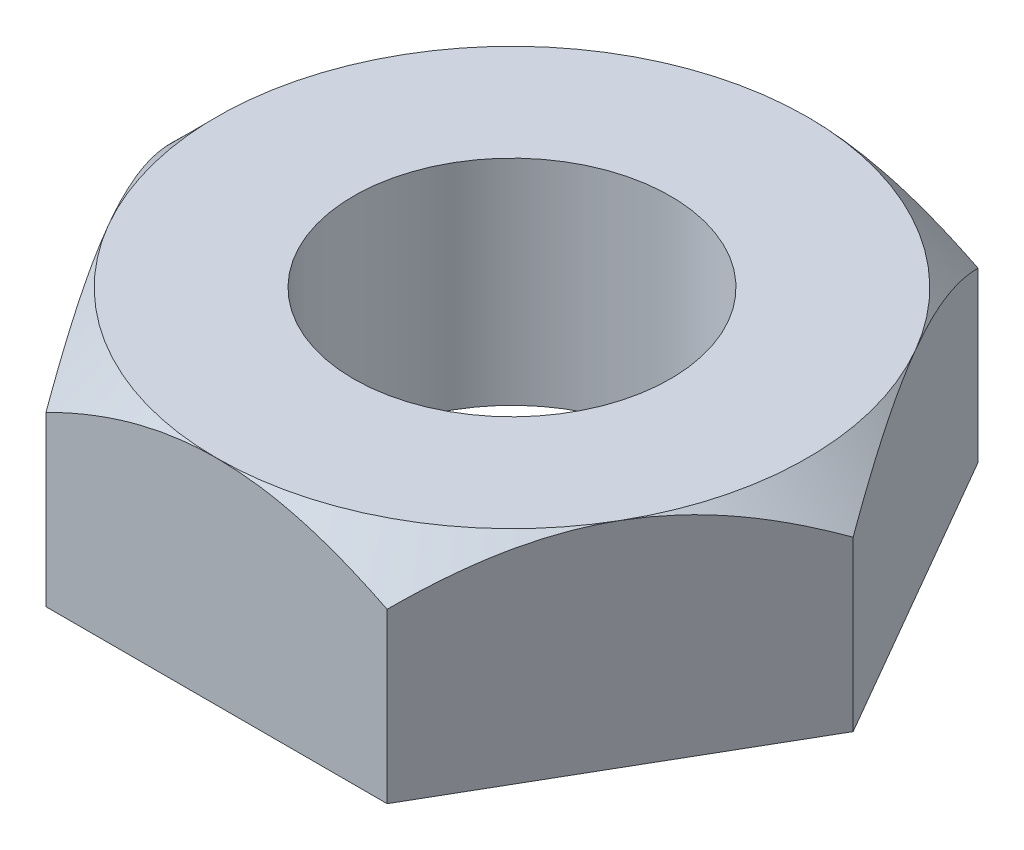
from build123d import *

# Parameters (mm, degrees)
SKETCH1_R                    = 18.5
BOSS_EXTRUDE1_DEPTH          = 25
SKETCH2_OUTSIDE_W            = 143.338
SKETCH2_OUTSIDE_H            = 132.664
SKETCH2_OUTSIDE_R            = 34.5
CUT_EXTRUDE1_DEPTH           = 10
CUT_EXTRUDE1_TAPER           = 45
CUT_EXTRUDE1_OTHER_WAY_DEPTH = 10
CUT_EXTRUDE1_OTHER_WAY_TAPER = 45


with BuildPart() as part:
    # Sketch1 → Boss-Extrude1 (new body)
    with BuildSketch(Plane(origin=(0, 0, 0), x_dir=(1, 0, 0), z_dir=(0, 1, 0))):
        Polygon((39.837168574, 0), (19.918584287, 34.5), (-19.918584287, 34.5), (-39.837168574, 0), (-19.918584287, -34.5), (19.918584287, -34.5), align=None)
        Circle(SKETCH1_R, mode=Mode.SUBTRACT)
    extrude(amount=BOSS_EXTRUDE1_DEPTH)

    # Sketch2 outside → Cut-Extrude1 (cut)
    with BuildSketch(Plane(origin=(0, 25, 0), x_dir=(1, 0, 0), z_dir=(0, 1, 0))):
        Rectangle(SKETCH2_OUTSIDE_W, SKETCH2_OUTSIDE_H)
        Circle(SKETCH2_OUTSIDE_R, mode=Mode.SUBTRACT)
    extrude(amount=CUT_EXTRUDE1_DEPTH, taper=CUT_EXTRUDE1_TAPER, mode=Mode.SUBTRACT)

    # Sketch2 outside → Cut-Extrude1 other way (cut)
    with BuildSketch(Plane(origin=(0, 25, 0), x_dir=(1, 0, 0), z_dir=(0, 1, 0))):
        Rectangle(SKETCH2_OUTSIDE_W, SKETCH2_OUTSIDE_H)
        Circle(SKETCH2_OUTSIDE_R, mode=Mode.SUBTRACT)
    extrude(amount=-CUT_EXTRUDE1_OTHER_WAY_DEPTH, taper=CUT_EXTRUDE1_OTHER_WAY_TAPER, mode=Mode.SUBTRACT)


solid = part.part
